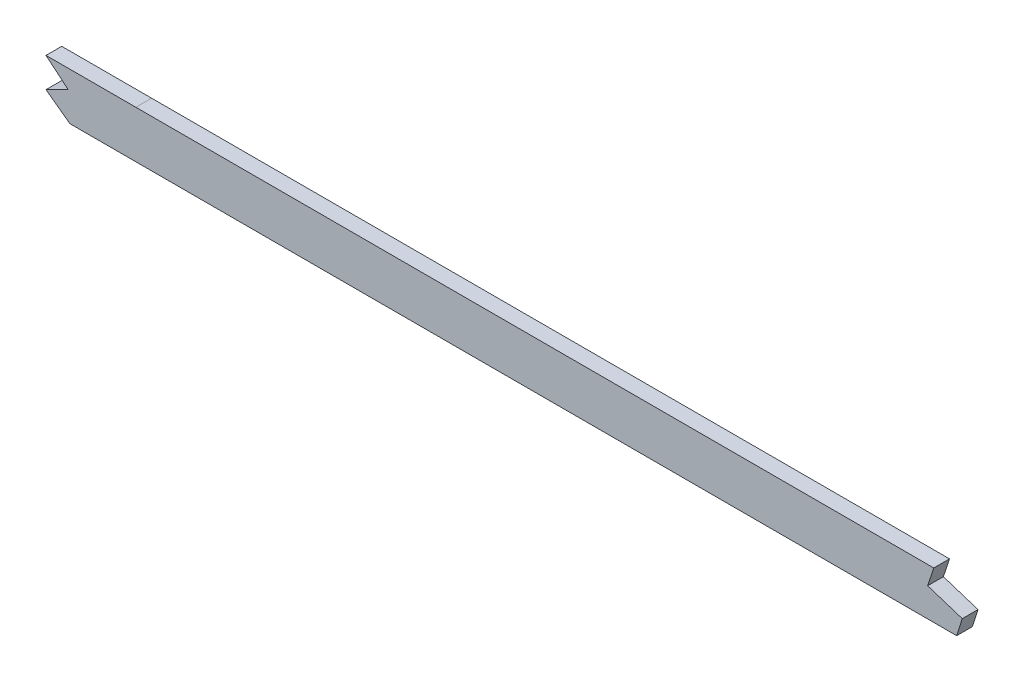
from build123d import *

# Parameters (mm, degrees)
BOSS_EXTRUDE1_DEPTH = 3.175
CUT_EXTRUDE1_DEPTH  = 7.3500001
FILLET1_R           = 2.54
CUT_EXTRUDE2_DEPTH  = 7.62


with BuildPart() as part:
    # Sketch1 → Boss-Extrude1 (new body, symmetric)
    with BuildSketch(Plane.XY):
        with BuildLine():
            Line((499.61002795, -53.470702797), (1046.28548189, -53.470702797))
            add(Edge.make_bspline(
                [(2669.54, -9.569049356), (2615.393603553, -13.17073937), (2561.080658619, -16.536108081), (2506.205230446, -19.758621957), (2430.209106802, -23.505211705), (2354.212983157, -26.631486423), (2332.570330468, -27.480988169), (2156.268639429, -34.377768543), (1979.966947376, -41.628631248), (1824.114277635, -52.771265877), (1636.928606778, -53.579569849), (1449.742935921, -53.454024613), (1418.006730935, -53.470702797), (1324.899336146, -53.470702797), (1231.791940344, -53.470702797), (1170.441269319, -53.470702797), (1108.784075813, -53.470702797), (1047.126882346, -53.470702797), (1046.846414188, -53.470702797), (1046.565947184, -53.470702797), (1046.28548189, -53.470702797)],
                knots=[103.698913506, 103.698913506, 103.698913506, 103.698913506, 103.698913506, 103.698913506, 130.927896619, 130.927896619, 130.927896619, 141.337054719, 141.337054719, 141.337054719, 218.101815019, 218.101815019, 218.101815019, 233.772059419, 233.772059419, 233.772059419, 264.077723219, 264.077723219, 264.077723219, 264.2162088, 264.2162088, 264.2162088, 264.2162088, 264.2162088, 264.2162088], degree=5))
            Line((2669.54, -9.569049356), (2669.54, 9.5231025))
            add(Edge.make_bspline(
                [(2669.54, 9.5231025), (2667.126494524, 9.36235515), (2659.861586685, 8.880281494), (2635.666282302, 7.292469146), (2596.857665529, 4.826056853), (2545.729743039, 1.758344093), (2494.405305707, -1.098555235), (2451.533022267, -3.266573297), (2417.198316756, -4.86708361), (2391.457076919, -6.003589235), (2365.634736307, -7.086854581), (2339.546284672, -8.137729944), (2313.466132974, -9.165138371), (2287.612375486, -10.179478215), (2261.763347437, -11.201032297), (2227.285329715, -12.583842557), (2184.175569393, -14.36607236), (2132.429066114, -16.607427868), (2063.4255234, -19.708920485), (1977.174907635, -23.700543313), (1873.732451432, -28.149389221), (1770.37461881, -31.657468649), (1667.085687813, -33.793117556), (1581.011094491, -34.383188831), (1512.07397126, -34.4278026), (1443.061513477, -34.409510402), (1356.800927879, -34.424432812), (1218.794626954, -34.418464788), (1115.289022786, -34.420702797), (1046.28548189, -34.420702797)],
                knots=[103.571582669, 103.571582669, 103.571582669, 103.571582669, 104.300777207, 105.766098403, 110.877392287, 115.98868617, 121.099980054, 126.211273938, 128.76692088, 131.322567822, 133.878214764, 136.433861706, 138.989508647, 141.545155589, 144.100802531, 146.656449473, 151.767743357, 156.879037241, 161.990331124, 172.212918892, 182.43550666, 192.658094427, 202.880682195, 213.103269962, 218.214563846, 223.32585773, 233.548445497, 243.771033265, 264.2162088, 264.2162088, 264.2162088, 264.2162088], degree=3))
            Line((1046.28548189, -34.420702797), (499.61002795, -34.420702797))
            add(Edge.make_bspline(
                [(499.61002795, -34.420702797), (488.614737518, -34.420702797), (472.236395365, -34.420702798), (449.940231846, -34.420702794), (427.771305695, -34.42070281), (405.874681663, -34.420702712), (384.584909128, -34.420702942), (368.900229326, -34.420702244), (353.376568613, -34.420704862), (332.608466435, -34.420689186), (306.287754853, -34.420570006), (274.023487704, -34.420538256), (252.271015965, -34.420709741), (241.425150134, -34.420702761)],
                knots=[19.90682951, 19.90682951, 19.90682951, 19.90682951, 23.220120017, 24.876765271, 26.533410525, 29.846701033, 31.503346286, 33.15999154, 34.816636794, 36.473282048, 39.786572556, 43.099863063, 46.413153571, 46.413153571, 46.413153571, 46.413153571], degree=3))
            add(Edge.make_bspline(
                [(241.425150134, -34.420702761), (239.394928853, -34.420701455), (235.322322927, -34.420495867), (227.274423443, -34.398702533), (217.319360062, -34.297466855), (205.530690077, -33.976385563), (189.963341914, -33.212641271), (170.696984653, -31.543495194), (147.533261232, -28.314398128), (125.482753206, -24.202109872), (109.358914834, -20.622537553), (100.964116069, -18.612521054), (99.06, -18.149327722)],
                knots=[0, 0, 0, 0, 0.622088422, 1.244176844, 2.488353689, 3.732530533, 4.976707377, 7.465061066, 9.953414755, 12.441768444, 14.55823542, 15.180323842, 15.180323842, 15.180323842, 15.180323842], degree=3))
            Line((99.06, -18.149327722), (99.06, -37.741485304))
            add(Edge.make_bspline(
                [(241.425137875, -53.470702761), (224.286916993, -53.470691732), (207.149474967, -53.467315374), (190.203897513, -52.686577078), (161.734965878, -49.987457476), (133.266034188, -45.175583375), (121.749620566, -42.910592695), (110.349390726, -40.420274627), (99.06, -37.741485304)],
                knots=[0, 0, 0, 0, 0, 0, 8.71381608, 8.71381608, 8.71381608, 14.701907176, 14.701907176, 14.701907176, 14.701907176, 14.701907176, 14.701907176], degree=5))
            add(Edge.make_bspline(
                [(499.61002795, -53.470702797), (492.136820835, -53.470702797), (484.754348064, -53.470702797), (477.443025859, -53.470702797), (448.516583145, -53.470702797), (419.590140517, -53.470702797), (398.368118521, -53.470702797), (355.647540186, -53.470702797), (312.926961851, -53.470702797), (289.235090436, -53.470293029), (265.364963651, -53.470705034), (241.4948369, -53.470702789), (241.471603891, -53.470702785), (241.448370882, -53.470702776), (241.425137875, -53.470702761)],
                knots=[19.90682951, 19.90682951, 19.90682951, 19.90682951, 19.90682951, 19.90682951, 23.637897311, 23.637897311, 23.637897311, 34.276545571, 34.276545571, 34.276545571, 46.401340901, 46.401340901, 46.401340901, 46.413153571, 46.413153571, 46.413153571, 46.413153571, 46.413153571, 46.413153571], degree=5))
        make_face()
    extrude(amount=BOSS_EXTRUDE1_DEPTH, both=True)

    # Sketch2 → Cut-Extrude1 (cut, through all)
    with BuildSketch(Plane.XY.offset(3.175)):
        with BuildLine():
            add(Edge.make_bspline(
                [(2312.9875, -9.183260037), (2304.505441691, -9.516700376), (2287.441020622, -10.186250162), (2261.763347437, -11.201032297), (2228.230552004, -12.545932515), (2203.310445107, -13.575047161), (2187.00995947, -14.263260037)],
                knots=[139.04033329, 139.04033329, 139.04033329, 139.04033329, 141.545155589, 144.100802531, 146.656449473, 151.487488909, 151.487488909, 151.487488909, 151.487488909], degree=3))
            Line((2187.00995947, -14.263260037), (2312.9875, -14.263260037))
            Line((2312.9875, -14.263260037), (2312.9875, -9.183260037))
        make_face()
    extrude(amount=-CUT_EXTRUDE1_DEPTH, mode=Mode.SUBTRACT)

    # Fillet1
    fillet1_edges = [part.edges().sort_by_distance(p)[0] for p in [
        (2669.54, -9.569049356, -1.5875),
        (2669.54, 9.5231025, -1.5875),
        (99.06, -37.741485304, -1.5875),
        (99.06, -18.149327722, -1.5875),
        (2312.9875, -9.183260037, 1.5875),
        (2312.9875, -14.263260037, 0),
    ]]
    fillet(fillet1_edges, radius=FILLET1_R)

    # Sketch3 → Cut-Extrude2 (cut)
    with BuildSketch(Plane.XY.offset(3.175)):
        Polygon((463.358597157, -34.420702797), (472.271656585, -41.874419167), (463.358597157, -46.384200616), (472.997412797, -53.470702797), (65.960080016, -189.871321367), (36.237397513, 16.701322029), (463.358597157, 108.26369674), align=None)
        Polygon((821.518882755, -34.420702797), (819.047328197, -41.874419167), (833.004793216, -46.384200616), (830.756310042, -53.470702797), (830.756310042, -93.67118026), (2725.490502614, -272.22369225), (2725.490502614, 129.691463791), (821.518882755, 129.691463791), align=None)
    extrude(amount=-CUT_EXTRUDE2_DEPTH, mode=Mode.SUBTRACT)


solid = part.part
